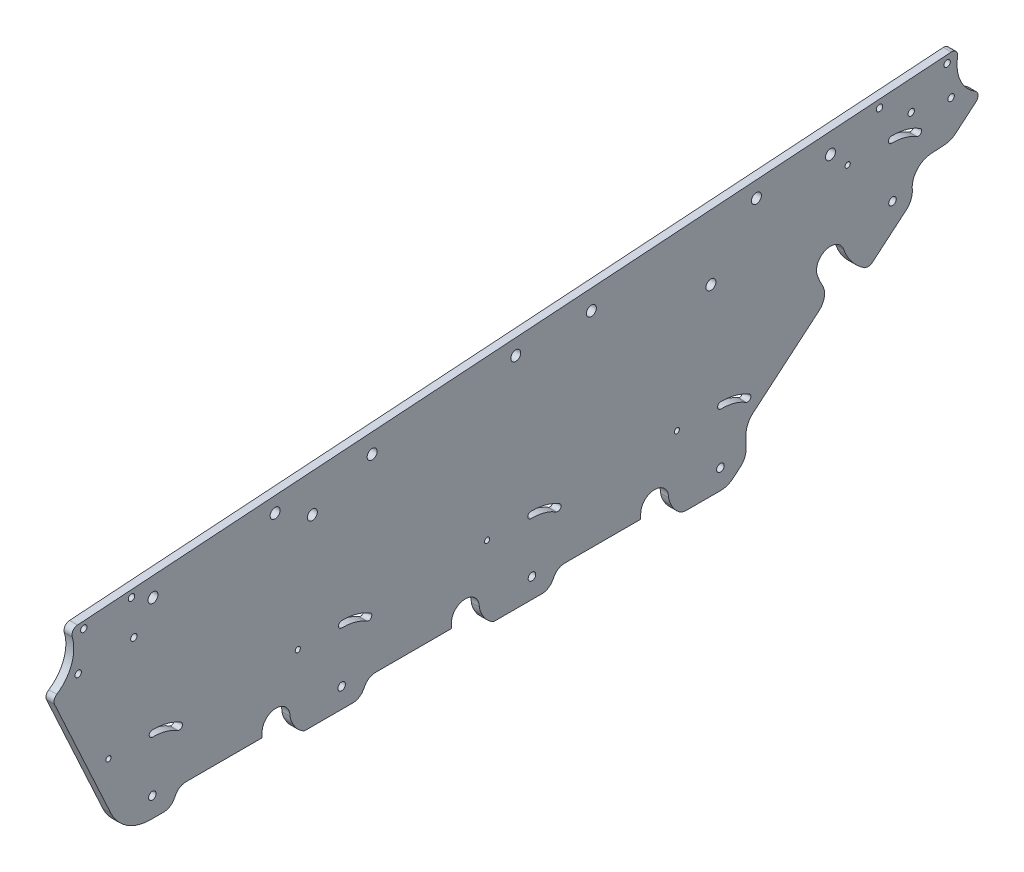
from build123d import *

# Parameters (mm, degrees)
SKETCH_1_R      = 2.5
SKETCH_1_R_2    = 1.6
SKETCH_1_R_3    = 1.3
SKETCH_1_R_4    = 1.9
EXTRUDE_1_DEPTH = 4


with BuildPart() as part:
    # 草图1 → 凸台-拉伸1 (new body)
    with BuildSketch(Plane.ZY):
        with BuildLine():
            Line((79.941847196, 312.779286974), (79.941847196, 310.37938842))
            Line((79.941847196, 310.37938842), (118.048778684, 310.37938842))
            ThreePointArc((118.048778684, 310.37938842), (121.212295154, 309.477639448), (123.424912382, 307.043442935))
            ThreePointArc((123.424912382, 307.043442935), (123.908451597, 306.156590075), (124.459804418, 305.310228312))
            ThreePointArc((124.459804418, 305.310228312), (126.599767036, 303.449448704), (129.355274977, 302.779286974))
            Line((129.355274977, 302.779286974), (135.846674735, 302.779286974))
            ThreePointArc((135.846674735, 302.779286974), (147.714917725, 306.255118752), (155.832977431, 315.5843044))
            Line((155.832977431, 315.5843044), (184.100349844, 377.02653737))
            ThreePointArc((184.100349844, 377.02653737), (184.25423495, 379.122829036), (182.994670387, 380.805569803))
            ThreePointArc((182.994670387, 380.805569803), (175.575423742, 390.035917566), (175.217785471, 401.873004854))
            ThreePointArc((175.217785471, 401.873004854), (174.813539386, 404.446095635), (172.549129806, 405.733208807))
            Line((172.549129806, 405.733208807), (-265.913463366, 435.515010668))
            ThreePointArc((-265.913463366, 435.515010668), (-268.349260645, 434.525893618), (-269.070634733, 431.997835004))
            ThreePointArc((-269.070634733, 431.997835004), (-270.458967767, 420.871071163), (-277.882819523, 412.467573839))
            ThreePointArc((-277.882819523, 412.467573839), (-279.312515533, 410.13392022), (-278.252765969, 407.610648385))
            Line((-278.252765969, 407.610648385), (-268.246230566, 399.190213281))
            ThreePointArc((-268.246230566, 399.190213281), (-265.544431584, 397.566061892), (-262.471282959, 396.863678095))
            Line((-262.471282959, 396.863678095), (-255.629318556, 396.408593428))
            ThreePointArc((-255.629318556, 396.408593428), (-248.6530075, 392.882824378), (-246.344722675, 385.41477346))
            ThreePointArc((-246.344722675, 385.41477346), (-245.547224173, 381.106497376), (-242.780709967, 377.708903254))
            Line((-242.780709967, 377.708903254), (-225.96618646, 363.559589999))
            ThreePointArc((-225.96618646, 363.559589999), (-224.259021966, 363.148943594), (-222.527086507, 363.437804541))
            ThreePointArc((-222.527086507, 363.437804541), (-216.093640019, 369.198004343), (-211.901591148, 376.74756471))
            ThreePointArc((-211.901591148, 376.74756471), (-202.96771311, 381.012048641), (-198.703229179, 372.078170603))
            ThreePointArc((-198.703229179, 372.078170603), (-199.907426668, 369.068297365), (-201.351406018, 366.165823913))
            ThreePointArc((-201.351406018, 366.165823913), (-202.203284687, 360.847165515), (-199.49001514, 356.193995329))
            Line((-199.49001514, 356.193995329), (-166.466058225, 328.404548243))
            ThreePointArc((-166.466058225, 328.404548243), (-163.838636178, 324.972953793), (-162.904676824, 320.753130691))
            Line((-162.904676824, 320.753130691), (-162.904676824, 314.217366152))
            ThreePointArc((-162.904676824, 314.217366152), (-162.15750934, 310.841507671), (-160.055571702, 308.096232111))
            Line((-160.055571702, 308.096232111), (-156.52807865, 305.127869423))
            ThreePointArc((-156.52807865, 305.127869423), (-153.516253341, 303.384762625), (-150.089460052, 302.779286974))
            Line((-150.089460052, 302.779286974), (-132.962822931, 302.779286974))
            ThreePointArc((-132.962822931, 302.779286974), (-131.057359543, 303.089892518), (-129.349178653, 303.989550548))
            ThreePointArc((-129.349178653, 303.989550548), (-127.378799895, 305.843763559), (-125.854682643, 308.079286974))
            ThreePointArc((-125.854682643, 308.079286974), (-124.70730834, 310.334067306), (-124.058152804, 312.779286974))
            ThreePointArc((-124.058152804, 312.779286974), (-117.058152804, 319.779286974), (-110.058152804, 312.779286974))
            Line((-110.058152804, 312.779286974), (-110.058152804, 310.375194841))
            Line((-110.058152804, 310.375194841), (-71.897768127, 310.375194841))
            ThreePointArc((-71.897768127, 310.375194841), (-68.768086545, 309.494285893), (-66.557393134, 307.110225907))
            ThreePointArc((-66.557393134, 307.110225907), (-65.945300527, 306.047683601), (-65.231544729, 305.050584724))
            ThreePointArc((-65.231544729, 305.050584724), (-63.141167069, 303.376870223), (-60.530823557, 302.779286974))
            Line((-60.530823557, 302.779286974), (-36.305637158, 302.779286974))
            ThreePointArc((-36.305637158, 302.779286974), (-33.16644373, 305.003787341), (-30.854682657, 308.079286974))
            ThreePointArc((-30.854682657, 308.079286974), (-29.707305648, 310.334074366), (-29.058150487, 312.779301913))
            ThreePointArc((-29.058150487, 312.779301913), (-22.058145334, 319.779284657), (-15.058155121, 312.779286974))
            Line((-15.058155121, 312.779286974), (-15.058155121, 310.354804619))
            Line((-15.058155121, 310.354804619), (23.075565874, 310.354804619))
            ThreePointArc((23.075565874, 310.354804619), (26.234507213, 309.455891721), (28.446910847, 307.028501158))
            ThreePointArc((28.446910847, 307.028501158), (28.930044794, 306.145924462), (29.48046838, 305.303669209))
            ThreePointArc((29.48046838, 305.303669209), (31.619349297, 303.447603066), (34.37128438, 302.779286974))
            Line((34.37128438, 302.779286974), (58.694362842, 302.779286974))
            ThreePointArc((58.694362842, 302.779286974), (61.833556273, 305.00378734), (64.14531735, 308.079286974))
            ThreePointArc((64.14531735, 308.079286974), (65.292691668, 310.334067319), (65.941847214, 312.779287004))
            ThreePointArc((65.941847214, 312.779287004), (72.94184722, 319.77928698), (79.941847196, 312.779286974))
        make_face()
        with Locations((134.697589837, 398.714435962)):
            Circle(SKETCH_1_R, mode=Mode.SUBTRACT)
        with Locations((-205.302410163, 421.329108832)):
            Circle(SKETCH_1_R, mode=Mode.SUBTRACT)
        with Locations((24.697589837, 406.030947773)):
            Circle(SKETCH_1_R, mode=Mode.SUBTRACT)
        with Locations((54.697589837, 394.714435962)):
            Circle(SKETCH_1_R, mode=Mode.SUBTRACT)
        with Locations((-145.302410163, 394.714435962)):
            Circle(SKETCH_1_R, mode=Mode.SUBTRACT)
        with Locations((-85.302410163, 413.347459584)):
            Circle(SKETCH_1_R, mode=Mode.SUBTRACT)
        with Locations((-229.912547558, 429.226877683)):
            Circle(SKETCH_1_R_2, mode=Mode.SUBTRACT)
        with Locations((-263.830685058, 431.584832)):
            Circle(SKETCH_1_R_2, mode=Mode.SUBTRACT)
        with Locations((-245.82758059, 419.331621378)):
            Circle(SKETCH_1_R_2, mode=Mode.SUBTRACT)
        with Locations((-213.924753581, 412.419296618)):
            Circle(SKETCH_1_R_3, mode=Mode.SUBTRACT)
        with Locations((-265.82758059, 415.709933316)):
            Circle(SKETCH_1_R_2, mode=Mode.SUBTRACT)
        with Locations((145.452321386, 404.165877908)):
            Circle(SKETCH_1_R_2, mode=Mode.SUBTRACT)
        with Locations((172.223627163, 384.384644706)):
            Circle(SKETCH_1_R_2, mode=Mode.SUBTRACT)
        with Locations((169.397149412, 402.539467503)):
            Circle(SKETCH_1_R_2, mode=Mode.SUBTRACT)
        with Locations((144.282792088, 386.203912503)):
            Circle(SKETCH_1_R_2, mode=Mode.SUBTRACT)
        with Locations((-236.412834805, 385.419296624)):
            Circle(SKETCH_1_R_4, mode=Mode.SUBTRACT)
        with Locations((-128.211318153, 339.779286974)):
            Circle(SKETCH_1_R_3, mode=Mode.SUBTRACT)
        with Locations((62, 339.779286968)):
            Circle(SKETCH_1_R_3, mode=Mode.SUBTRACT)
        with Locations((40, 312.779286974)):
            Circle(SKETCH_1_R_4, mode=Mode.SUBTRACT)
        with Locations((-47.3651173, 412.828527404)):
            Circle(SKETCH_1_R, mode=Mode.SUBTRACT)
        with Locations((-55.488081224, 312.779286974)):
            Circle(SKETCH_1_R_4, mode=Mode.SUBTRACT)
        with Locations((-33, 339.779286968)):
            Circle(SKETCH_1_R_3, mode=Mode.SUBTRACT)
        with Locations((-168.130178692, 420.86106375)):
            Circle(SKETCH_1_R, mode=Mode.SUBTRACT)
        with Locations((73.399944092, 404.795991058)):
            Circle(SKETCH_1_R, mode=Mode.SUBTRACT)
        with Locations((157, 339.779286968)):
            Circle(SKETCH_1_R_3, mode=Mode.SUBTRACT)
        with Locations((-150.058152804, 312.779286974)):
            Circle(SKETCH_1_R_4, mode=Mode.SUBTRACT)
        with Locations((135, 312.779286974)):
            Circle(SKETCH_1_R_4, mode=Mode.SUBTRACT)
        with BuildLine():
            ThreePointArc((-235.893747688, 414.018996163), (-243.357483185, 413.10813588), (-250.274012295, 410.158790343))
            ThreePointArc((-250.274012295, 410.158790343), (-250.815185629, 407.961716967), (-248.618112252, 407.420543633))
            ThreePointArc((-248.618112252, 407.420543633), (-242.527853555, 410.017551036), (-235.955759474, 410.819597073))
            ThreePointArc((-235.955759474, 410.819597073), (-234.325054036, 412.388290724), (-235.893747688, 414.018996163))
        make_face(mode=Mode.SUBTRACT)
        with BuildLine():
            ThreePointArc((-54.968994107, 341.378986513), (-62.432729604, 340.468126231), (-69.349258714, 337.518780694))
            ThreePointArc((-69.349258714, 337.518780694), (-69.890432048, 335.321707317), (-67.693358671, 334.780533983))
            ThreePointArc((-67.693358671, 334.780533983), (-61.603099974, 337.377541387), (-55.031005893, 338.179587423))
            ThreePointArc((-55.031005893, 338.179587423), (-53.400300455, 339.748281075), (-54.968994107, 341.378986513))
        make_face(mode=Mode.SUBTRACT)
        with BuildLine():
            ThreePointArc((-150.180312259, 341.378986519), (-157.644047756, 340.468126237), (-164.560576866, 337.5187807))
            ThreePointArc((-164.560576866, 337.5187807), (-165.1017502, 335.321707323), (-162.904676824, 334.780533989))
            ThreePointArc((-162.904676824, 334.780533989), (-156.814418127, 337.377541393), (-150.242324046, 338.179587429))
            ThreePointArc((-150.242324046, 338.179587429), (-148.611618608, 339.748281081), (-150.180312259, 341.378986519))
        make_face(mode=Mode.SUBTRACT)
        with BuildLine():
            ThreePointArc((40.031005893, 341.378986513), (32.567270396, 340.468126231), (25.650741286, 337.518780694))
            ThreePointArc((25.650741286, 337.518780694), (25.109567952, 335.321707317), (27.306641329, 334.780533983))
            ThreePointArc((27.306641329, 334.780533983), (33.396900026, 337.377541387), (39.968994107, 338.179587423))
            ThreePointArc((39.968994107, 338.179587423), (41.599699545, 339.748281075), (40.031005893, 341.378986513))
        make_face(mode=Mode.SUBTRACT)
        with BuildLine():
            ThreePointArc((135.031005893, 341.378986513), (127.567270396, 340.468126231), (120.650741287, 337.518780694))
            ThreePointArc((120.650741287, 337.518780694), (120.109567952, 335.321707317), (122.306641329, 334.780533983))
            ThreePointArc((122.306641329, 334.780533983), (128.396900026, 337.377541387), (134.968994107, 338.179587423))
            ThreePointArc((134.968994107, 338.179587423), (136.599699545, 339.748281075), (135.031005893, 341.378986513))
        make_face(mode=Mode.SUBTRACT)
    extrude(amount=EXTRUDE_1_DEPTH)


solid = part.part
